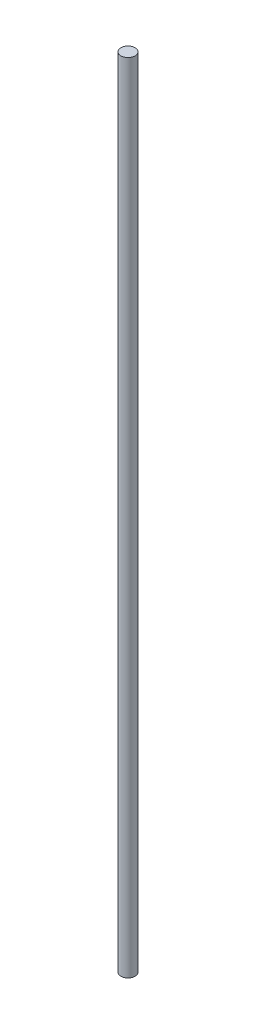
from build123d import *

# Parameters (mm, degrees)
SKETCH1_W = 4
SKETCH1_H = 450


with BuildPart() as part:
    # Sketch1 → Revolve1 (revolve)
    with BuildSketch(Plane.XY):
        with Locations((2, 225)):
            Rectangle(SKETCH1_W, SKETCH1_H)
    revolve(axis=Axis((0, 0, 0), (0, 1, 0)))


solid = part.part
